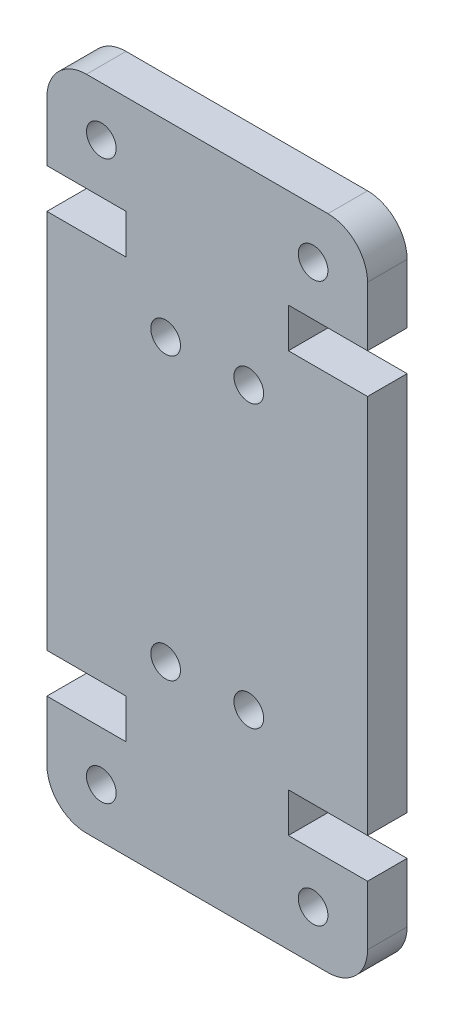
from build123d import *

# Parameters (mm, degrees)
SKETCH1_R           = 0.75
BOSS_EXTRUDE1_DEPTH = 2


with BuildPart() as part:
    # Sketch1 → Boss-Extrude1 (new body)
    with BuildSketch(Plane.XY):
        with BuildLine():
            Line((0, 26.21), (0, 7))
            Line((0, 7), (4, 7))
            Line((4, 7), (4, 5))
            Line((4, 5), (0, 5))
            Line((0, 5), (0, 2))
            ThreePointArc((0, 2), (0.585786438, 0.585786438), (2, 0))
            Line((2, 0), (14.2, 0))
            ThreePointArc((14.2, 0), (15.614213562, 0.585786438), (16.2, 2))
            Line((16.2, 2), (16.2, 5))
            Line((16.2, 5), (12.2, 5))
            Line((12.2, 5), (12.2, 7))
            Line((12.2, 7), (16.2, 7))
            Line((16.2, 7), (16.2, 26.21))
            Line((16.2, 26.21), (12.2, 26.21))
            Line((12.2, 26.21), (12.2, 28.21))
            Line((12.2, 28.21), (16.2, 28.21))
            Line((16.2, 28.21), (16.2, 31.21))
            ThreePointArc((16.2, 31.21), (15.614213562, 32.624213562), (14.2, 33.21))
            Line((14.2, 33.21), (2, 33.21))
            ThreePointArc((2, 33.21), (0.585786438, 32.624213562), (0, 31.21))
            Line((0, 31.21), (0, 28.21))
            Line((0, 28.21), (4, 28.21))
            Line((4, 28.21), (4, 26.21))
            Line((4, 26.21), (0, 26.21))
        make_face()
        with Locations((13.45, 2.5)):
            Circle(SKETCH1_R, mode=Mode.SUBTRACT)
        with Locations((10.2, 9.5)):
            Circle(SKETCH1_R, mode=Mode.SUBTRACT)
        with Locations((2.75, 30.71)):
            Circle(SKETCH1_R, mode=Mode.SUBTRACT)
        with Locations((6, 23.71)):
            Circle(SKETCH1_R, mode=Mode.SUBTRACT)
        with Locations((6, 9.5)):
            Circle(SKETCH1_R, mode=Mode.SUBTRACT)
        with Locations((2.75, 2.5)):
            Circle(SKETCH1_R, mode=Mode.SUBTRACT)
        with Locations((10.2, 23.71)):
            Circle(SKETCH1_R, mode=Mode.SUBTRACT)
        with Locations((13.45, 30.71)):
            Circle(SKETCH1_R, mode=Mode.SUBTRACT)
    extrude(amount=BOSS_EXTRUDE1_DEPTH)


solid = part.part
